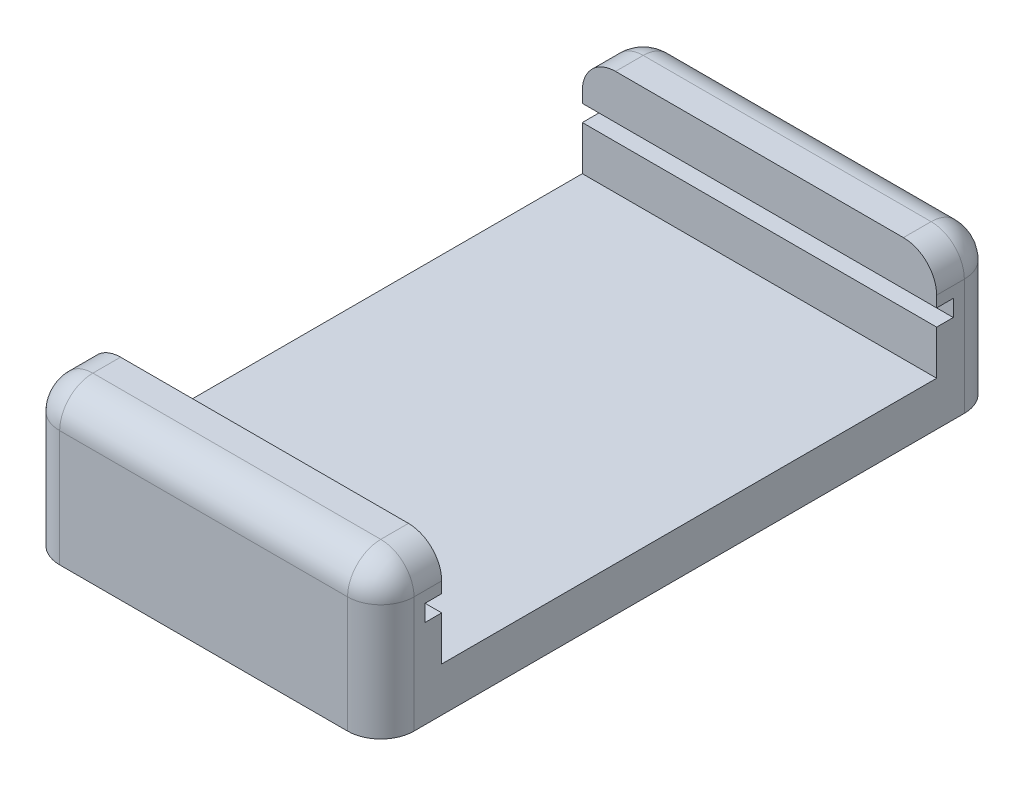
from build123d import *

# Parameters (mm, degrees)
SKETCH2_W               = 88.9
SKETCH2_H               = 152.4
BOSS_EXTRUDE1_DEPTH     = 5.9944
SKETCH4_R               = 2.7305
CUT_EXTRUDE2_DEPTH      = 1
CUT_EXTRUDE2_DEPTH_BACK = 6.9944
BOSS_EXTRUDE3_DEPTH     = 20.32
FILLET3_R               = 3.81
FILLET6_R               = 3.81
SKETCH7_W               = 2.54
SKETCH7_H               = 152.4
CUT_EXTRUDE3_DEPTH      = 18.145
CUT_EXTRUDE3_DEPTH_BACK = 6.9944
SKETCH8_W               = 86.36
SKETCH8_H               = 152.4
SKETCH8_R               = 2.7305
CUT_EXTRUDE5_DEPTH      = 5.9944
SKETCH9_R               = 2.7305
CUT_EXTRUDE6_DEPTH      = 4.064


with BuildPart() as part:
    # Sketch2 → Boss-Extrude1 (new body)
    with BuildSketch(Plane(origin=(0, 0, 0), x_dir=(1, 0, 0), z_dir=(0, 1, 0))):
        with Locations((44.45, 76.2)):
            Rectangle(SKETCH2_W, SKETCH2_H)
    extrude(amount=BOSS_EXTRUDE1_DEPTH)

    # Sketch4 → Cut-Extrude2 (cut, two sides)
    with BuildSketch(Plane(origin=(0, 5.9944, 0), x_dir=(1, 0, 0), z_dir=(0, 1, 0))) as cut_extrude2_sk:
        with Locations((45.72, 109.871331367)):
            Circle(SKETCH4_R)
        with Locations((45.72, 33.671331367)):
            Circle(SKETCH4_R)
    extrude(amount=CUT_EXTRUDE2_DEPTH, mode=Mode.SUBTRACT)
    extrude(cut_extrude2_sk.sketch, amount=-CUT_EXTRUDE2_DEPTH_BACK, mode=Mode.SUBTRACT)

    # Sketch6 → Boss-Extrude3 (add, symmetric)
    with BuildSketch(Plane.ZY.offset(-44.45)):
        Polygon((-149.86, 5.9944), (-79.121, 5.9944), (-79.121, 23.1394), (-86.106, 23.1394), (-86.106, 18.0594), (-84.201, 18.0594), (-84.201, 16.1544), (-86.106, 16.1544), (-86.106, 11.0744), (-142.875, 11.0744), (-142.875, 16.1544), (-144.78, 16.1544), (-144.78, 18.0594), (-142.875, 18.0594), (-142.875, 23.1394), (-149.86, 23.1394), align=None)
    extrude(amount=BOSS_EXTRUDE3_DEPTH, both=True)

    # Fillet3
    fillet3_edges = [part.edges().sort_by_distance(p)[0] for p in [
        (44.45, 23.1394, -149.86),
        (44.45, 23.1394, -79.121),
    ]]
    fillet(fillet3_edges, radius=FILLET3_R)

    # Fillet6
    fillet6_edges = [part.edges().sort_by_distance(p)[0] for p in [
        (24.13, 12.6619, -149.86),
        (64.77, 12.6619, -79.121),
        (24.13, 23.1394, -84.5185),
        (24.13, 12.6619, -79.121),
        (64.77, 23.1394, -84.5185),
        (64.77, 12.6619, -149.86),
        (64.77, 23.1394, -144.4625),
        (64.77, 22.023476836, -148.744076836),
        (64.77, 22.023476836, -80.236923164),
        (24.13, 23.1394, -144.4625),
        (24.13, 22.023476836, -148.744076836),
        (24.13, 22.023476836, -80.236923164),
    ]]
    fillet(fillet6_edges, radius=FILLET6_R)

    # Sketch7 → Cut-Extrude3 (cut, two sides)
    with BuildSketch(Plane(origin=(0, 5.9944, 0), x_dir=(1, 0, 0), z_dir=(0, 1, 0))) as cut_extrude3_sk:
        with Locations((1.27, 76.2)):
            Rectangle(SKETCH7_W, SKETCH7_H)
    extrude(amount=CUT_EXTRUDE3_DEPTH, mode=Mode.SUBTRACT)
    extrude(cut_extrude3_sk.sketch, amount=-CUT_EXTRUDE3_DEPTH_BACK, mode=Mode.SUBTRACT)

    # Sketch8 → Cut-Extrude5 (cut)
    with BuildSketch(Plane.XZ):
        with Locations((45.72, -76.2)):
            Rectangle(SKETCH8_W, SKETCH8_H)
        with Locations((45.72, -33.671331367)):
            Circle(SKETCH8_R, mode=Mode.SUBTRACT)
        with Locations((45.72, -109.871331367)):
            Circle(SKETCH8_R, mode=Mode.SUBTRACT)
    extrude(amount=-CUT_EXTRUDE5_DEPTH, mode=Mode.SUBTRACT)

    # Sketch9 → Cut-Extrude6 (cut)
    with BuildSketch(Plane.XZ.offset(-5.9944)):
        with Locations((44.45, -89.0905)):
            Circle(SKETCH9_R)
        with Locations((44.45, -139.8905)):
            Circle(SKETCH9_R)
    extrude(amount=-CUT_EXTRUDE6_DEPTH, mode=Mode.SUBTRACT)


solid = part.part
